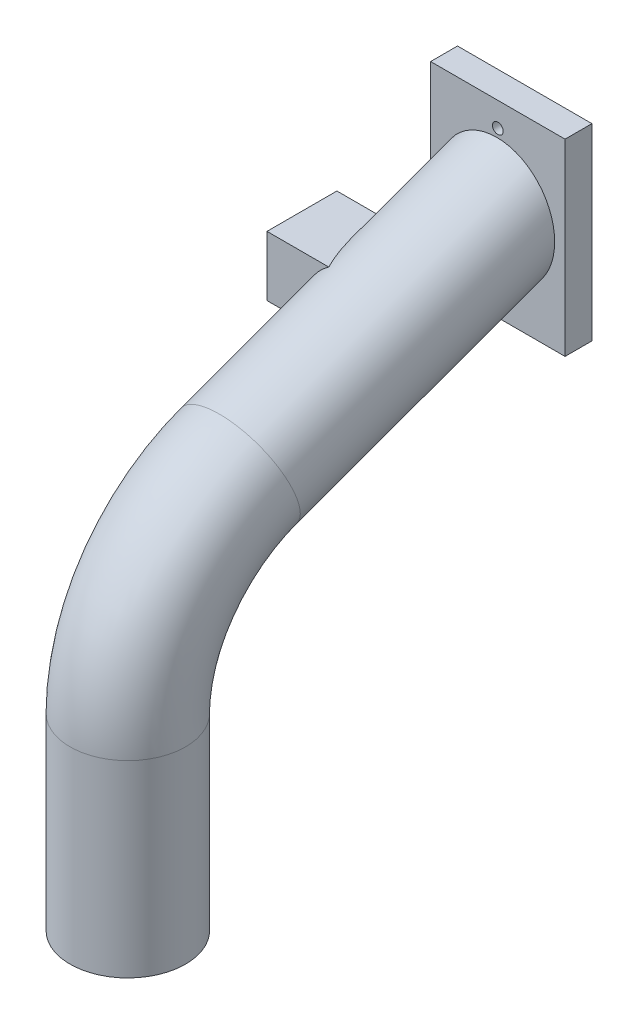
from build123d import *

# Parameters (mm, degrees)
ESQUISSE1_W                         = 50
ESQUISSE1_H                         = 70
ESQUISSE1_R                         = 2
ESQUISSE1_R_2                       = 20
BOSS_EXTRU_1_DEPTH                  = 10
BOSS_EXTRU_2_REACH                  = 57.317
ESQUISSE13_R                        = 21.5
ESQUISSE13_R_2                      = 20
BOSS_EXTRU_2_DIRECTION_2_DEPTH      = 90
ESQUISSE19_R                        = 21.5
ESQUISSE19_R_2                      = 20
R_VOLUTION5_ANGLE                   = 70
ESQUISSE23_R                        = 21.5
ESQUISSE23_R_2                      = 20
BOSS_EXTRU_3_DEPTH                  = 70
ESQUISSE24_W                        = 23
ESQUISSE24_H                        = 16.3
ENL_V_MAT_EXTRU_1_DEPTH             = 10
BOSS_EXTRU_4_DEPTH                  = 13
BOSS_EXTRU_4_DIRECTION_2_REACH      = 242.506
BOSS_EXTRU_4_DIRECTION_2_END_RADIUS = 21.5
ESQUISSE28_W                        = 4
ESQUISSE28_H                        = 4
BOSS_EXTRU_5_DEPTH                  = 23


with BuildPart() as part:
    # Esquisse1 → Boss.-Extru.1 (new body)
    with BuildSketch(Plane.XY):
        with Locations((-5.186655458, -0.726415094)):
            Rectangle(ESQUISSE1_W, ESQUISSE1_H)
        with Locations((-5.186655458, 25.273584906)):
            Circle(ESQUISSE1_R, mode=Mode.SUBTRACT)
        with Locations((-5.186655458, -30.726415094)):
            Circle(ESQUISSE1_R, mode=Mode.SUBTRACT)
        with Locations((-5.186655458, -0.726415094)):
            Circle(ESQUISSE1_R_2, mode=Mode.SUBTRACT)
    extrude(amount=BOSS_EXTRU_1_DEPTH)

    # Boss.-Extru.2: up to this plane
    boss_extru_2_end = Plane(origin=(0, 0, 10), z_dir=(0, 0, 1))
    # Esquisse13 → Boss.-Extru.2 (add, up to the surface)
    with BuildSketch(Plane(origin=(0, -7.393134718, 20.312470696), x_dir=(1, 0, 0), z_dir=(0, -0.34202014332566283, 0.9396926207859106)), mode=Mode.PRIVATE) as boss_extru_2_sk1:
        with Locations(Location((-5.554517745, 2.737594529, 0), (0, 0, 270))):
            Circle(ESQUISSE13_R)
        with Locations(Location((-5.554517745, 2.737594529, 0), (0, 0, 29.306498897))):
            Circle(ESQUISSE13_R_2, mode=Mode.SUBTRACT)
    boss_extru_2_tool1 = split(extrude(boss_extru_2_sk1.sketch, amount=-BOSS_EXTRU_2_REACH, mode=Mode.PRIVATE), bisect_by=boss_extru_2_end, keep=Keep.BOTH, mode=Mode.PRIVATE)
    add(boss_extru_2_tool1.solids().sort_by_distance((-5.554518, 14.811316, 28.39423))[0])

    # Esquisse13 → Boss.-Extru.2 direction 2 (add)
    with BuildSketch(Plane(origin=(0, -7.393134718, 20.312470696), x_dir=(1, 0, 0), z_dir=(0, -0.34202014332566283, 0.9396926207859106))):
        with Locations(Location((-5.554517745, 2.737594529, 0), (0, 0, 270))):
            Circle(ESQUISSE13_R)
        with Locations(Location((-5.554517745, 2.737594529, 0), (0, 0, 29.306498897))):
            Circle(ESQUISSE13_R_2, mode=Mode.SUBTRACT)
    extrude(amount=BOSS_EXTRU_2_DIRECTION_2_DEPTH)

    # Esquisse19 → R_volution5 (revolve)
    with BuildSketch(Plane(origin=(0, -38.174947617, 104.884806567), x_dir=(1, 0, 0), z_dir=(0, -0.34202014332566294, 0.9396926207859106))):
        with Locations(Location((-5.554517745, 2.737594529, 0), (0, 0, 90))):
            Circle(ESQUISSE19_R)
        with Locations(Location((-5.554517745, 2.737594529, 0), (0, 0, 90))):
            Circle(ESQUISSE19_R_2, mode=Mode.SUBTRACT)
    revolve(axis=Axis((-5.554579986, -94.784211414, 84.280719561), (1, 0, 0)), revolution_arc=R_VOLUTION5_ANGLE)

    # Esquisse23 → Boss.-Extru.3 (add)
    with BuildSketch(Plane.XZ.offset(94.784211414)):
        with Locations(Location((-5.554579986, 147.260634339, 0), (0, 0, 270))):
            Circle(ESQUISSE23_R)
        with Locations(Location((-5.554579986, 147.260634339, 0), (0, 0, 270.000178307))):
            Circle(ESQUISSE23_R_2, mode=Mode.SUBTRACT)
    extrude(amount=BOSS_EXTRU_3_DEPTH)

    # Esquisse24 → Enl_v. mat.-Extru.1 (cut)
    with BuildSketch(Plane.ZY.offset(27.186655458)):
        with Locations((46.360115203, -11.15)):
            Rectangle(ESQUISSE24_W, ESQUISSE24_H)
    extrude(amount=-ENL_V_MAT_EXTRU_1_DEPTH, mode=Mode.SUBTRACT)



with BuildPart() as body_2:
    # Esquisse27 → Boss.-Extru.4 (new body)
    with BuildSketch(Plane.ZY.offset(27.186655458)):
        Polygon((60.860115203, 0), (34.860115203, 0), (34.860115203, -3), (57.860115203, -3), (57.860115203, -19.3), (34.860115203, -19.3), (34.860115203, -22.3), (60.860115203, -22.3), align=None)
    extrude(amount=BOSS_EXTRU_4_DEPTH)

    # Boss.-Extru.4 direction 2: up to this cylinder (the profile starts outside it)
    boss_extru_4_direction_2_end = Plane(origin=(-5.554517745, -12.849515831, 43.307945529), z_dir=(0, 0.34202014332566283, -0.9396926207859105)) * Cylinder(BOSS_EXTRU_4_DIRECTION_2_END_RADIUS, 529.012, mode=Mode.PRIVATE)
    # Esquisse27 → Boss.-Extru.4 direction 2 (add, up to the surface)
    with BuildSketch(Plane.ZY.offset(27.186655458), mode=Mode.PRIVATE) as boss_extru_4_direction_2_sk1:
        Polygon((60.860115203, 0), (34.860115203, 0), (34.860115203, -3), (57.860115203, -3), (57.860115203, -19.3), (34.860115203, -19.3), (34.860115203, -22.3), (60.860115203, -22.3), align=None)
    boss_extru_4_direction_2_tool1 = extrude(boss_extru_4_direction_2_sk1.sketch, amount=-BOSS_EXTRU_4_DIRECTION_2_REACH, mode=Mode.PRIVATE) - boss_extru_4_direction_2_end
    add(boss_extru_4_direction_2_tool1.solids().sort_by_distance((-27.186655, -0.342533, 47.860115))[0])


with BuildPart() as part_1:
    add(part.part)

    add(body_2.part)  # Boss.-Extru.5 merges body 2
    # Esquisse28 → Boss.-Extru.5 (add)
    with BuildSketch(Plane(origin=(0, 0, 34.860115203), x_dir=(-1, 0, 0), z_dir=(0, 0, -1))):
        with Locations((31.138517686, -5)):
            Rectangle(ESQUISSE28_W, ESQUISSE28_H)
        with Locations((36.938517686, -5)):
            Rectangle(ESQUISSE28_W, ESQUISSE28_H)
        with Locations((31.138517686, -17.3)):
            Rectangle(ESQUISSE28_W, ESQUISSE28_H)
        with Locations((36.938517686, -17.3)):
            Rectangle(ESQUISSE28_W, ESQUISSE28_H)
    extrude(amount=-BOSS_EXTRU_5_DEPTH)


solid = part_1.part
